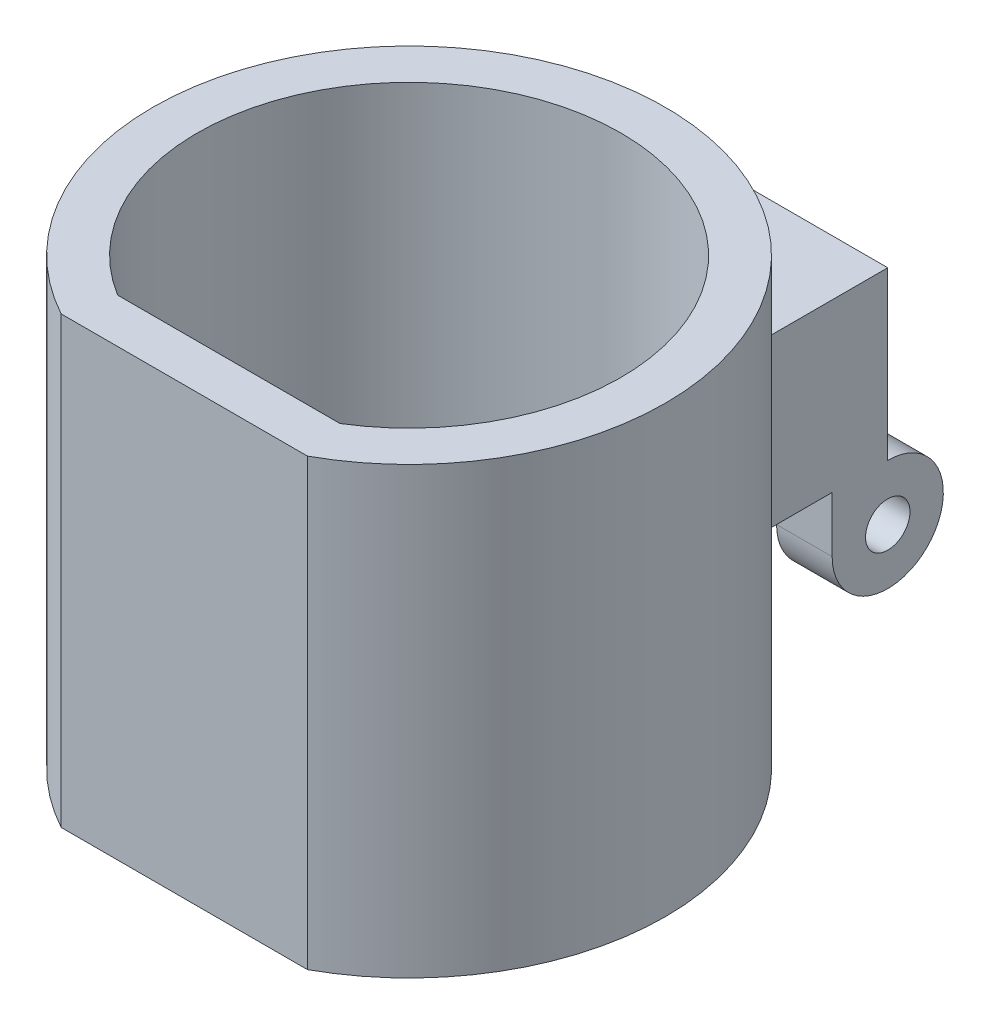
from build123d import *

# Parameters (mm, degrees)
BOSS_EXTRUDE1_DEPTH             = 20
BOSS_EXTRUDE2_REACH             = 54.944
BOSS_EXTRUDE2_END_RADIUS        = 23.05
SKETCH2_W                       = 20
SKETCH2_H                       = 15
BOSS_EXTRUDE2_DIRECTION_2_DEPTH = 10
SKETCH3_R                       = 2
BOSS_EXTRUDE3_DEPTH             = 5


with BuildPart() as part:
    # Sketch1 → Boss-Extrude1 (new, symmetric)
    with BuildSketch(Plane(origin=(0, 0, 0), x_dir=(1, 0, 0), z_dir=(0, 1, 0))):
        with BuildLine():
            Line((-11.076364599, -20.214268408), (11.076364599, -20.214268408))
            ThreePointArc((11.076364599, -20.214268408), (0, 23.05), (-11.076364599, -20.214268408))
        make_face()
        with BuildLine():
            Line((-10, -16.214268408), (10, -16.214268408))
            ThreePointArc((10, -16.214268408), (0, 19.05), (-10, -16.214268408))
        make_face(mode=Mode.SUBTRACT)
    extrude(amount=BOSS_EXTRUDE1_DEPTH, both=True)

    # Boss-Extrude2: up to this cylinder (the profile starts outside it)
    boss_extrude2_end = Plane(origin=(0, 0, 0), z_dir=(0, -1, 0)) * Cylinder(BOSS_EXTRUDE2_END_RADIUS, 156.988, mode=Mode.PRIVATE)
    # Sketch2 → Boss-Extrude2 (add, up to the surface)
    with BuildSketch(Plane(origin=(0, 0, -23.05), x_dir=(-1, 0, 0), z_dir=(0, 0, -1)), mode=Mode.PRIVATE) as boss_extrude2_sk1:
        Rectangle(SKETCH2_W, SKETCH2_H)
    boss_extrude2_tool1 = extrude(boss_extrude2_sk1.sketch, amount=-BOSS_EXTRUDE2_REACH, mode=Mode.PRIVATE) - boss_extrude2_end
    add(boss_extrude2_tool1.solids().sort_by_distance((0, 0, -23.05))[0])
    add(boss_extrude2_tool1.solids().sort_by_distance((0, 0, -23.05))[1])

    # Sketch2 → Boss-Extrude2 direction 2 (add)
    with BuildSketch(Plane(origin=(0, 0, -23.05), x_dir=(-1, 0, 0), z_dir=(0, 0, -1))):
        Rectangle(SKETCH2_W, SKETCH2_H)
    extrude(amount=BOSS_EXTRUDE2_DIRECTION_2_DEPTH)

    # Sketch3 → Boss-Extrude3 (add)
    with BuildSketch(Plane(origin=(10, 0, 0), x_dir=(0, 0, -1), z_dir=(1, 0, 0))):
        with BuildLine():
            Line((28.05, -12.5), (28.05, -7.5))
            Line((28.05, -7.5), (33.05, -7.5))
            ThreePointArc((33.05, -7.5), (36.585533906, -16.035533906), (28.05, -12.5))
        make_face()
        with Locations((33.05, -12.5)):
            Circle(SKETCH3_R, mode=Mode.SUBTRACT)
    boss_extrude3 = extrude(amount=-BOSS_EXTRUDE3_DEPTH)

    # Mirror1: Boss-Extrude3 across plane
    add(boss_extrude3.mirror(Plane(origin=(0, 0, 0), x_dir=(0, 0, 1), z_dir=(1, 0, 0))))


solid = part.part
